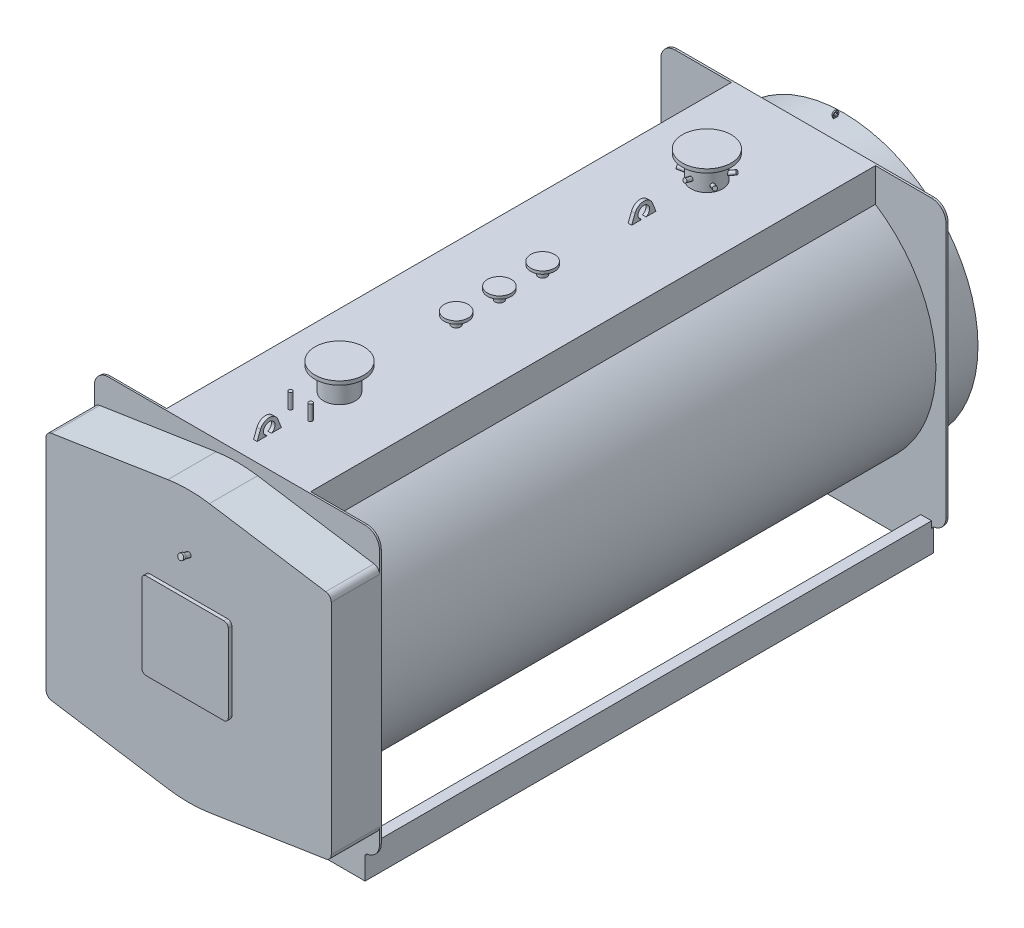
from build123d import *

# Parameters (mm, degrees)
PIASTRA_ANTERIORE_DEPTH       = 12
CORPO_DEPTH                   = 3920
PIASTRA_POSTERIORE_DEPTH      = 14
BASAMENTO_DEPTH               = 3920
SCHIZZO24_R                   = 13.35
ESTRUSIONE_ESTRUSIONE12_DEPTH = 298
SCHIZZO25_R                   = 81
ESTRUSIONE_ESTRUSIONE13_DEPTH = 8
SCHIZZO31_R                   = 12.5
ESTRUSIONE_ESTRUSIONE15_DEPTH = 4
SCHIZZO11_R                   = 16.85
SCHIZZO21_R                   = 109.55
ESTRUSIONE_ESTRUSIONE9_DEPTH  = 1191
SCHIZZO22_R                   = 170
ESTRUSIONE_ESTRUSIONE10_DEPTH = 26
SCHIZZO21_4_R                 = 30.15
ESTRUSIONE_ESTRUSIONE11_DEPTH = 1085
SCHIZZO35_R                   = 82.5
ESTRUSIONE_ESTRUSIONE16_DEPTH = 20
SCHIZZO21_6_R                 = 13.35
ESTRUSIONE_ESTRUSIONE18_DEPTH = 1110
RIPETIZIONECIRCOLARE1_COUNT   = 3
ESTRUSIONE_ESTRUSIONE5_DEPTH  = 335
ESTRUSIONE_ESTRUSIONE6_DEPTH  = 25
SCHIZZO37_R                   = 40
ESTRUSIONE_ESTRUSIONE17_DEPTH = 12.5


with BuildPart() as part:
    # Schizzo1 → piastra anteriore (new body)
    with BuildSketch(Plane.XY):
        with BuildLine():
            Line((-890, 2140), (890, 2140))
            ThreePointArc((890, 2140), (960.710678119, 2110.710678119), (990, 2040))
            Line((990, 2040), (990, 268.601329718))
            ThreePointArc((990, 268.601329718), (966.376261583, 204.051607282), (906.666666667, 170))
            ThreePointArc((906.666666667, 170), (894.724747683, 163.189678544), (890, 150.279734056))
            Line((890, 150.279734056), (890, 0))
            Line((890, 0), (-890, 0))
            Line((-890, 0), (-890, 150.279734056))
            ThreePointArc((-890, 150.279734056), (-894.724747683, 163.189678544), (-906.666666667, 170))
            ThreePointArc((-906.666666667, 170), (-966.376261583, 204.051607282), (-990, 268.601329718))
            Line((-990, 268.601329718), (-990, 2040))
            ThreePointArc((-990, 2040), (-960.710678119, 2110.710678119), (-890, 2140))
        make_face()
    extrude(amount=-PIASTRA_ANTERIORE_DEPTH)

    # Schizzo2 → corpo (add)
    with BuildSketch(Plane(origin=(0, 0, -12), x_dir=(-1, 0, 0), z_dir=(0, 0, -1))):
        with BuildLine():
            Line((500, 1907.269383052), (500, 2140))
            Line((500, 2140), (-500, 2140))
            Line((-500, 2140), (-500, 1907.269383052))
            ThreePointArc((-500, 1907.269383052), (0, 215), (500, 1907.269383052))
        make_face()
    extrude(amount=CORPO_DEPTH)

    # Schizzo3 → piastra posteriore (add)
    with BuildSketch(Plane(origin=(0, 0, -3932), x_dir=(-1, 0, 0), z_dir=(0, 0, -1))):
        with BuildLine():
            Line((-890, 150.279734056), (-890, 0))
            Line((-890, 0), (890, 0))
            Line((890, 0), (890, 150.279734056))
            ThreePointArc((890, 150.279734056), (894.724747683, 163.189678544), (906.666666667, 170))
            ThreePointArc((906.666666667, 170), (966.376261583, 204.051607282), (990, 268.601329718))
            Line((990, 268.601329718), (990, 2040))
            ThreePointArc((990, 2040), (960.710678119, 2110.710678119), (890, 2140))
            Line((890, 2140), (-890, 2140))
            ThreePointArc((-890, 2140), (-960.710678119, 2110.710678119), (-990, 2040))
            Line((-990, 2040), (-990, 268.601329718))
            ThreePointArc((-990, 268.601329718), (-966.376261583, 204.051607282), (-906.666666667, 170))
            ThreePointArc((-906.666666667, 170), (-894.724747683, 163.189678544), (-890, 150.279734056))
        make_face()
    extrude(amount=PIASTRA_POSTERIORE_DEPTH)

    # Schizzo4 → basamento (add)
    with BuildSketch(Plane(origin=(0, 0, -12), x_dir=(-1, 0, 0), z_dir=(0, 0, -1))):
        Polygon((-815, 0), (-890, 0), (-890, 200), (-815, 200), (-815, 192), (-882, 192), (-882, 8), (-815, 8), align=None)
    extrude(amount=BASAMENTO_DEPTH)

    # Schizzo23 → camera-fumo (revolve)
    with BuildSketch(Plane(origin=(0, 0, 0), x_dir=(0, 0, -1), z_dir=(1, 0, 0))):
        Polygon((3946, 2070), (4209, 2070), (4209, 1434), (4254, 1434), (4254, 1475), (4259, 1475), (4259, 1429), (4204, 1429), (4204, 2065), (3946, 2065), align=None)
    revolve(axis=Axis((0, 1135, -4219.232253574), (0, 0, 1)))

    # Schizzo24 → Estrusione-Estrusione12 (add)
    with BuildSketch(Plane(origin=(0, 0, -3946), x_dir=(-1, 0, 0), z_dir=(0, 0, -1))):
        with Locations(Location((0, 215.5, 0), (0, 0, 270))):  # turned: the seam where the file's is
            Circle(SCHIZZO24_R)
    extrude(amount=ESTRUSIONE_ESTRUSIONE12_DEPTH)

    # Schizzo25 → Estrusione-Estrusione13 (add)
    with BuildSketch(Plane(origin=(0, 0, -4209), x_dir=(-1, 0, 0), z_dir=(0, 0, -1))):
        with Locations(Location((0, 395, 0), (0, 0, 270))):  # turned: the seam where the file's is
            Circle(SCHIZZO25_R)
    extrude(amount=ESTRUSIONE_ESTRUSIONE13_DEPTH)

    # Schizzo31 → Estrusione-Estrusione15 (add, symmetric)
    with BuildSketch(Plane(origin=(0, 0, 0), x_dir=(0, 0, -1), z_dir=(1, 0, 0))):
        with BuildLine():
            Line((4139, 2065), (4139, 2076.771243445))
            ThreePointArc((4139, 2076.771243445), (4154, 2110), (4169, 2076.771243445))
            Line((4169, 2076.771243445), (4169, 2065))
            Line((4169, 2065), (4139, 2065))
        make_face()
        with Locations((4154, 2090)):
            Circle(SCHIZZO31_R, mode=Mode.SUBTRACT)
    extrude(amount=ESTRUSIONE_ESTRUSIONE15_DEPTH, both=True)

    # Sweep1: sweep along a path in Schizzo10
    with BuildLine(Plane(origin=(0, 0, 0), x_dir=(0, 0, -1), z_dir=(1, 0, 0))) as sweep1_path:
        Line((3802, 320), (3802, 120))
        ThreePointArc((3802, 120), (3819.573593129, 77.573593129), (3862, 60))
        Line((3862, 60), (4357, 60))
    # Schizzo11 → Sweep1 (sweep)
    with BuildSketch(Plane(origin=(0, 60, -4357), x_dir=(-1, 0, 0), z_dir=(0, 0, -1))):
        Circle(SCHIZZO11_R)
    sweep(path=sweep1_path.line)

    # Schizzo21 → Estrusione-Estrusione9 (add)
    with BuildSketch(Plane(origin=(0, 1135, 0), x_dir=(1, 0, 0), z_dir=(0, 1, 0))):
        with Locations(Location((0, 712, 0), (0, 0, 270))):  # turned: the seam where the file's is
            Circle(SCHIZZO21_R)
        with Locations(Location((0, 3262, 0), (0, 0, 270))):  # turned: the seam where the file's is
            Circle(SCHIZZO21_R)
    extrude(amount=ESTRUSIONE_ESTRUSIONE9_DEPTH)

    # Schizzo22 → Estrusione-Estrusione10 (add)
    with BuildSketch(Plane(origin=(0, 2326, 0), x_dir=(1, 0, 0), z_dir=(0, 1, 0))):
        with Locations(Location((0, 712, 0), (0, 0, 270))):  # turned: the seam where the file's is
            Circle(SCHIZZO22_R)
        with Locations(Location((0, 3262, 0), (0, 0, 270))):  # turned: the seam where the file's is
            Circle(SCHIZZO22_R)
    extrude(amount=-ESTRUSIONE_ESTRUSIONE10_DEPTH)

    # Schizzo21_4 → Estrusione-Estrusione11 (add)
    with BuildSketch(Plane(origin=(0, 1135, 0), x_dir=(1, 0, 0), z_dir=(0, 1, 0))):
        with Locations(Location((0, 2122, 0), (0, 0, 270))):  # turned: the seam where the file's is
            Circle(SCHIZZO21_4_R)
        with Locations(Location((0, 1522, 0), (0, 0, 270))):  # turned: the seam where the file's is
            Circle(SCHIZZO21_4_R)
        with Locations(Location((0, 1822, 0), (0, 0, 270))):  # turned: the seam where the file's is
            Circle(SCHIZZO21_4_R)
    extrude(amount=ESTRUSIONE_ESTRUSIONE11_DEPTH)

    # Schizzo35 → Estrusione-Estrusione16 (add)
    with BuildSketch(Plane(origin=(0, 2220, 0), x_dir=(1, 0, 0), z_dir=(0, 1, 0))):
        with Locations(Location((0, 1522, 0), (0, 0, 270))):  # turned: the seam where the file's is
            Circle(SCHIZZO35_R)
        with Locations(Location((0, 1822, 0), (0, 0, 270))):  # turned: the seam where the file's is
            Circle(SCHIZZO35_R)
        with Locations(Location((0, 2122, 0), (0, 0, 270))):  # turned: the seam where the file's is
            Circle(SCHIZZO35_R)
    extrude(amount=-ESTRUSIONE_ESTRUSIONE16_DEPTH)

    # Schizzo21_6 → Estrusione-Estrusione18 (add)
    with BuildSketch(Plane(origin=(0, 1135, 0), x_dir=(1, 0, 0), z_dir=(0, 1, 0))):
        with Locations(Location((-70, 442, 0), (0, 0, 270))):  # turned: the seam where the file's is
            Circle(SCHIZZO21_6_R)
        with Locations(Location((70, 442, 0), (0, 0, 270))):  # turned: the seam where the file's is
            Circle(SCHIZZO21_6_R)
    extrude(amount=ESTRUSIONE_ESTRUSIONE18_DEPTH)

    # Schizzo9 → Rivoluzione3 (revolve)
    with BuildSketch(Plane(origin=(0, 0, 0), x_dir=(0, 0, -1), z_dir=(1, 0, 0))):
        Polygon((3353.55, 2190.101379163), (3411.505549577, 2205.630521869), (3414.986665734, 2192.638819505), (3357.031116157, 2177.109676799), align=None)
    rivoluzione3 = revolve(axis=Axis((0, 2181, -3371.55), (0, -0.258819045, 0.965925826)))

    # Schizzo34 → Rivoluzione5 (revolve)
    with BuildSketch(Plane(origin=(0, 0, 0), x_dir=(0, 0, -1), z_dir=(1, 0, 0))):
        Polygon((3112.494450423, 2225.630521869), (3170.45, 2210.101379163), (3166.968883843, 2197.109676799), (3109.013334266, 2212.638819505), align=None)
    rivoluzione5 = revolve(axis=Axis((0, 2201, -3152.45), (0, 0.258819045, 0.965925826)))

    # RipetizioneCircolare1: Rivoluzione3, Rivoluzione5 ×3 about axis
    ripetizionecircolare1_axis = Axis((0, 0, -3262), (0, 1, 0))
    add([rivoluzione3.rotate(ripetizionecircolare1_axis, i * 360 / RIPETIZIONECIRCOLARE1_COUNT) for i in range(1, RIPETIZIONECIRCOLARE1_COUNT)])
    add([rivoluzione5.rotate(ripetizionecircolare1_axis, i * 360 / RIPETIZIONECIRCOLARE1_COUNT) for i in range(1, RIPETIZIONECIRCOLARE1_COUNT)])

    # Schizzo33 → Rivoluzione4 (revolve)
    with BuildSketch(Plane(origin=(0, 0, 0), x_dir=(0, 0, -1), z_dir=(1, 0, 0)), mode=Mode.PRIVATE) as rivoluzione4_sk:
        Polygon((803.55, 2215.101379163), (861.505549577, 2230.630521869), (864.986665734, 2217.638819505), (807.031116157, 2202.109676799), align=None)
    revolve(rivoluzione4_sk.sketch.rotate(Axis((0, 2206, -821.55), (0, 0.258819045, -0.965925826)), 180), axis=Axis((0, 2206, -821.55), (0, 0.258819045, -0.965925826)))  # turned: the seam where the file's is

    # Schizzo14 → Estrusione-Estrusione5 (add)
    with BuildSketch(Plane.XY):
        with BuildLine():
            Line((-990, 1894), (-990, 376))
            ThreePointArc((-990, 376), (-979.173710049, 346.722747029), (-951.904109267, 331.532784265))
            Line((-951.904109267, 331.532784265), (-144.219171349, 206.129271311))
            ThreePointArc((-144.219171349, 206.129271311), (0, 195), (144.219171349, 206.129271311))
            Line((144.219171349, 206.129271311), (951.904109267, 331.532784265))
            ThreePointArc((951.904109267, 331.532784265), (979.173710049, 346.722747029), (990, 376))
            Line((990, 376), (990, 1894))
            ThreePointArc((990, 1894), (979.173710049, 1923.277252971), (951.904109267, 1938.467215735))
            Line((951.904109267, 1938.467215735), (144.219171349, 2063.870728689))
            ThreePointArc((144.219171349, 2063.870728689), (0, 2075), (-144.219171349, 2063.870728689))
            Line((-144.219171349, 2063.870728689), (-951.904109267, 1938.467215735))
            ThreePointArc((-951.904109267, 1938.467215735), (-979.173710049, 1923.277252971), (-990, 1894))
        make_face()
    extrude(amount=ESTRUSIONE_ESTRUSIONE5_DEPTH)

    # Schizzo15 → Estrusione-Estrusione6 (add)
    with BuildSketch(Plane.XY.offset(335)):
        with BuildLine():
            Line((-270, 1435), (270, 1435))
            ThreePointArc((270, 1435), (291.213203436, 1426.213203436), (300, 1405))
            Line((300, 1405), (300, 865))
            ThreePointArc((300, 865), (291.213203436, 843.786796564), (270, 835))
            Line((270, 835), (-270, 835))
            ThreePointArc((-270, 835), (-291.213203436, 843.786796564), (-300, 865))
            Line((-300, 865), (-300, 1405))
            ThreePointArc((-300, 1405), (-291.213203436, 1426.213203436), (-270, 1435))
        make_face()
    extrude(amount=ESTRUSIONE_ESTRUSIONE6_DEPTH)

    # Schizzo18 → Rivoluzione2 (revolve)
    with BuildSketch(Plane(origin=(0, 0, 0), x_dir=(0, 0, -1), z_dir=(1, 0, 0))):
        Polygon((-370.241857968, 1711.887431022), (-369.426577976, 1714.930097375), (-384.881391196, 1719.071202097), (-390.057772098, 1699.752685571), (-315, 1679.641016151), (-310.63889909, 1695.916866324), align=None)
    revolve(axis=Axis((0, 1685, 335), (0, 0.258819045, 0.965925826)))

    # Schizzo37 → Estrusione-Estrusione17 (add, symmetric)
    with BuildSketch(Plane(origin=(0, 0, 0), x_dir=(0, 0, -1), z_dir=(1, 0, 0))):
        with BuildLine():
            Line((117, 2062), (117, 2112))
            Line((117, 2112), (151.41509434, 2200.547169811))
            ThreePointArc((151.41509434, 2200.547169811), (212, 2242), (272.58490566, 2200.547169811))
            Line((272.58490566, 2200.547169811), (307, 2112))
            Line((307, 2112), (307, 2062))
            Line((307, 2062), (117, 2062))
        make_face()
        with Locations((212, 2177)):
            Circle(SCHIZZO37_R, mode=Mode.SUBTRACT)
        with BuildLine():
            Line((2717, 2062), (2717, 2112))
            Line((2717, 2112), (2751.41509434, 2200.547169811))
            ThreePointArc((2751.41509434, 2200.547169811), (2812, 2242), (2872.58490566, 2200.547169811))
            Line((2872.58490566, 2200.547169811), (2907, 2112))
            Line((2907, 2112), (2907, 2062))
            Line((2907, 2062), (2717, 2062))
        make_face()
        with Locations((2812, 2177)):
            Circle(SCHIZZO37_R, mode=Mode.SUBTRACT)
    extrude(amount=ESTRUSIONE_ESTRUSIONE17_DEPTH, both=True)


solid = part.part
